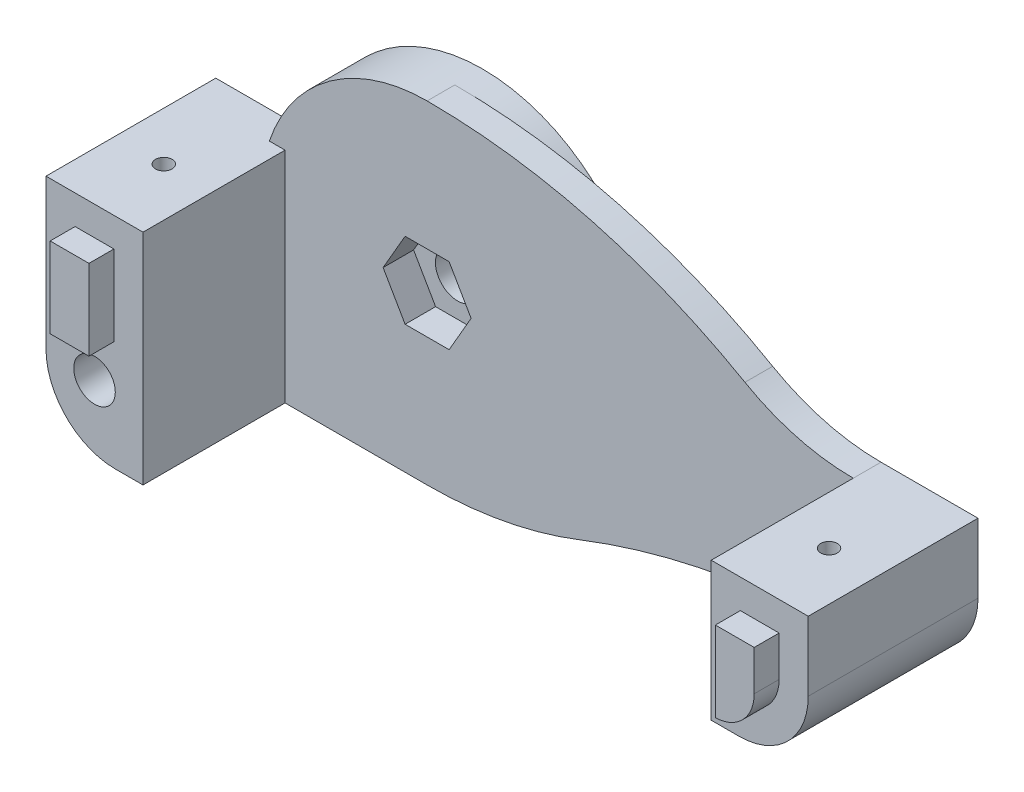
from build123d import *

# Parameters (mm, degrees)
SALIENTE_EXTRUIR1_DEPTH = 2
CROQUIS2_W              = 12.25
CROQUIS2_H              = 10
SALIENTE_EXTRUIR2_DEPTH = 7
REDONDEO1_R             = 5
CROQUIS3_R              = 0.6
CORTAR_EXTRUIR1_DEPTH   = 7.2
SALIENTE_EXTRUIR3_DEPTH = 1.8
CROQUIS5_W              = 12.25
CROQUIS5_H              = 15.8
SALIENTE_EXTRUIR4_DEPTH = 7
REDONDEO2_R             = 5
CROQUIS6_R              = 0.6
CORTAR_EXTRUIR2_DEPTH   = 9.8
CROQUIS7_W              = 2.8
CROQUIS7_H              = 5.8
SALIENTE_EXTRUIR5_DEPTH = 1.8
CROQUIS8_R              = 1.5
CORTAR_EXTRUIR3_DEPTH   = 13.8
CROQUIS9_R              = 3
CORTAR_EXTRUIR4_DEPTH   = 6
CROQUIS10_R             = 12
SALIENTE_EXTRUIR6_DEPTH = 2
CORTAR_EXTRUIR5_DEPTH   = 2.2
CROQUIS12_R             = 1.6
CORTAR_EXTRUIR6_DEPTH   = 4.2
CROQUIS14_R             = 1.6
SALIENTE_EXTRUIR7_DEPTH = 2


with BuildPart() as part:
    # Croquis1 → Saliente-Extruir1 (new body)
    with BuildSketch(Plane(origin=(0, 0, 45.55), x_dir=(-1, 0, 0), z_dir=(0, 0, -1))):
        with BuildLine():
            Line((-17.240678969, 0.142768675), (-17.240678969, -9.857231325))
            ThreePointArc((-17.240678969, -9.857231325), (-7.189890991, -10.796826624), (2.512589694, -13.583051105))
            ThreePointArc((2.512589694, -13.583051105), (7.914003263, -15.134154499), (13.509321031, -15.657231325))
            Line((13.509321031, -15.657231325), (25.509321031, -15.657231325))
            Line((25.509321031, -15.657231325), (25.509321031, -3.657231325))
            ThreePointArc((25.509321031, -3.657231325), (21.994602405, 4.82805005), (13.509321031, 8.342768675))
            ThreePointArc((13.509321031, 8.342768675), (1.641917085, 6.787620461), (-9.424079639, 2.227195163))
            ThreePointArc((-9.424079639, 2.227195163), (-13.195803851, 0.672823972), (-17.240678969, 0.142768675))
        make_face()
    extrude(amount=SALIENTE_EXTRUIR1_DEPTH)

    # Croquis2 → Saliente-Extruir2 (add)
    with BuildSketch(Plane(origin=(17.240678969, 0, 0), x_dir=(0, 0, -1), z_dir=(1, 0, 0))):
        with Locations((-49.675, -4.857231325)):
            Rectangle(CROQUIS2_W, CROQUIS2_H)
    extrude(amount=SALIENTE_EXTRUIR2_DEPTH)

    # Redondeo1
    redondeo1_edges = [part.edges().sort_by_distance(p)[0] for p in [
        (24.240678969, -9.857231325, 49.675),
    ]]
    fillet(redondeo1_edges, radius=REDONDEO1_R)

    # Croquis3 → Cortar-Extruir1 (cut)
    with BuildSketch(Plane(origin=(0, 0.142768675, 0), x_dir=(1, 0, 0), z_dir=(0, 1, 0))):
        with Locations(Location((20.740678969, -50.8, 0), (0, 0, 270))):
            Circle(CROQUIS3_R)
    extrude(amount=-CORTAR_EXTRUIR1_DEPTH, mode=Mode.SUBTRACT)

    # Croquis4 → Saliente-Extruir3 (add)
    with BuildSketch(Plane.XY.offset(55.8)):
        with BuildLine():
            Line((19.340678969, -1.957231325), (19.340678969, -7.755506674))
            ThreePointArc((19.340678969, -7.755506674), (21.32634433, -6.872175493), (22.140678969, -4.857231325))
            Line((22.140678969, -4.857231325), (22.140678969, -1.957231325))
            Line((22.140678969, -1.957231325), (19.340678969, -1.957231325))
        make_face()
    extrude(amount=SALIENTE_EXTRUIR3_DEPTH)

    # Croquis5 → Saliente-Extruir4 (add)
    with BuildSketch(Plane.ZY.offset(23.759321031)):
        with Locations((49.675, -7.757231325)):
            Rectangle(CROQUIS5_W, CROQUIS5_H)
    extrude(amount=SALIENTE_EXTRUIR4_DEPTH)

    # Redondeo2
    redondeo2_edges = [part.edges().sort_by_distance(p)[0] for p in [
        (-30.759321031, -15.657231325, 49.675),
    ]]
    fillet(redondeo2_edges, radius=REDONDEO2_R)

    # Croquis6 → Cortar-Extruir2 (cut)
    with BuildSketch(Plane(origin=(0, 0.142768675, 0), x_dir=(1, 0, 0), z_dir=(0, 1, 0))):
        with Locations(Location((-27.259321031, -50.8, 0), (0, 0, 270))):
            Circle(CROQUIS6_R)
    extrude(amount=-CORTAR_EXTRUIR2_DEPTH, mode=Mode.SUBTRACT)

    # Croquis7 → Saliente-Extruir5 (add)
    with BuildSketch(Plane.XY.offset(55.8)):
        with Locations((-27.259321031, -4.857231325)):
            Rectangle(CROQUIS7_W, CROQUIS7_H)
    extrude(amount=SALIENTE_EXTRUIR5_DEPTH)

    # Croquis8 → Cortar-Extruir3 (cut)
    with BuildSketch(Plane.XY.offset(55.8)):
        with Locations((-27.259321031, -10.857231325)):
            Circle(CROQUIS8_R)
    extrude(amount=-CORTAR_EXTRUIR3_DEPTH, mode=Mode.SUBTRACT)

    # Croquis9 → Cortar-Extruir4 (cut)
    with BuildSketch(Plane(origin=(0, 0, 43.55), x_dir=(-1, 0, 0), z_dir=(0, 0, -1))):
        with Locations((27.259321031, -10.857231325)):
            Circle(CROQUIS9_R)
    extrude(amount=-CORTAR_EXTRUIR4_DEPTH, mode=Mode.SUBTRACT)

    # Croquis10 → Saliente-Extruir6 (add)
    with BuildSketch(Plane(origin=(0, 0, 43.55), x_dir=(-1, 0, 0), z_dir=(0, 0, -1))):
        with Locations(Location((13.509321031, -3.657231325, 0), (0, 0, 90))):
            Circle(CROQUIS10_R)
    extrude(amount=SALIENTE_EXTRUIR6_DEPTH)

    # Croquis11 → Cortar-Extruir5 (cut)
    with BuildSketch(Plane.XY.offset(45.55)):
        Polygon((-15.097034272, -0.907231325), (-16.684747512, -3.657231325), (-15.097034272, -6.407231325), (-11.921607791, -6.407231325), (-10.333894551, -3.657231325), (-11.921607791, -0.907231325), align=None)
    extrude(amount=-CORTAR_EXTRUIR5_DEPTH, mode=Mode.SUBTRACT)

    # Croquis12 → Cortar-Extruir6 (cut)
    with BuildSketch(Plane.XY.offset(45.55)):
        with Locations((-13.509321031, -3.657231325)):
            Circle(CROQUIS12_R)
    extrude(amount=-CORTAR_EXTRUIR6_DEPTH, mode=Mode.SUBTRACT)

    # Croquis14 → Saliente-Extruir7 (add)
    with BuildSketch(Plane(origin=(0, 0, 41.55), x_dir=(-1, 0, 0), z_dir=(0, 0, -1))):
        Polygon((13.509321031, 0.961570829), (9.509321031, -1.347830248), (9.509321031, -5.966632401), (13.509321031, -8.276033478), (17.509321031, -5.966632401), (17.509321031, -1.347830248), align=None)
        with Locations(Location((13.509321031, -3.657231325, 0), (0, 0, 180))):
            Circle(CROQUIS14_R, mode=Mode.SUBTRACT)
    extrude(amount=SALIENTE_EXTRUIR7_DEPTH)


solid = part.part
